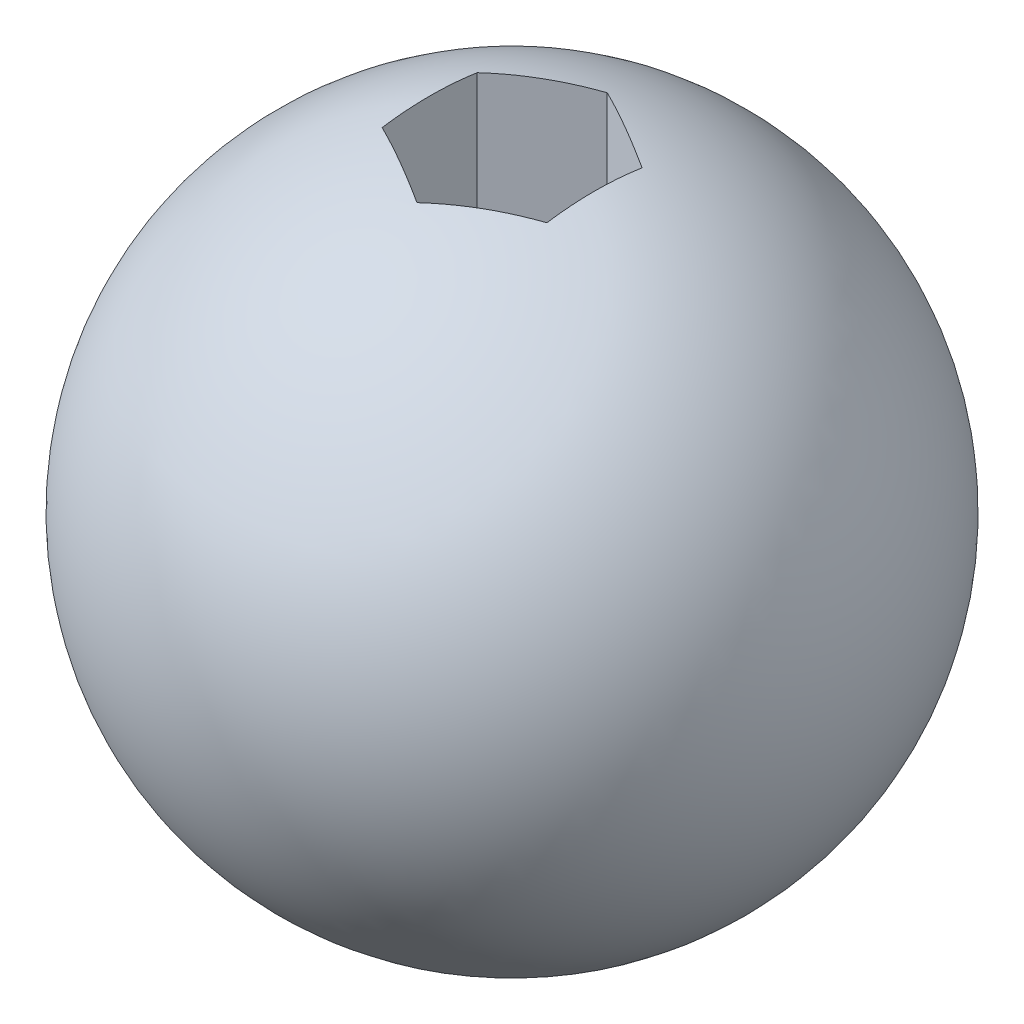
from build123d import *

# Parameters (mm, degrees)
ENL_V_MAT_EXTRU_1_DEPTH      = 21
ESQUISSE3_R                  = 3
ENL_V_MAT_EXTRU_2_DEPTH      = 21
ENL_V_MAT_EXTRU_3_DEPTH      = 21
ENL_V_MAT_EXTRU_3_DEPTH_BACK = 21


with BuildPart() as part:
    # Esquisse1 → Révolution1 (revolve)
    with BuildSketch(Plane.XY):
        with BuildLine():
            Line((0, 20), (0, -20))
            ThreePointArc((0, -20), (20, 0), (0, 20))
        make_face()
    revolve(axis=Axis((0, 38.8303663, 0), (0, -1, 0)))

    # Esquisse2 → Enlèv. mat.-Extru.1 (cut, through all)
    with BuildSketch(Plane(origin=(0, 0, 0), x_dir=(1, 0, 0), z_dir=(0, 1, 0))):
        Polygon((5, -2.886751346), (5, 2.886751346), (0, 5.773502692), (-5, 2.886751346), (-5, -2.886751346), (0, -5.773502692), align=None)
    extrude(amount=ENL_V_MAT_EXTRU_1_DEPTH, mode=Mode.SUBTRACT)

    # Esquisse3 → Enlèv. mat.-Extru.2 (cut, through all)
    with BuildSketch(Plane(origin=(0, 0, 0), x_dir=(1, 0, 0), z_dir=(0, 1, 0))):
        Circle(ESQUISSE3_R)
    extrude(amount=-ENL_V_MAT_EXTRU_2_DEPTH, mode=Mode.SUBTRACT)

    # Esquisse5 → Enlèv. mat.-Extru.3 (cut, two sides)
    with BuildSketch(Plane.XY) as enl_v_mat_extru_3_sk:
        Polygon((188.012399008, -16), (31.726859594, -16), (-44.024896915, -16), (-200.310436329, -16), (-200.310436329, -328.571078828), (188.012399008, -328.571078828), align=None)
    extrude(amount=ENL_V_MAT_EXTRU_3_DEPTH, mode=Mode.SUBTRACT)
    extrude(enl_v_mat_extru_3_sk.sketch, amount=-ENL_V_MAT_EXTRU_3_DEPTH_BACK, mode=Mode.SUBTRACT)


solid = part.part
